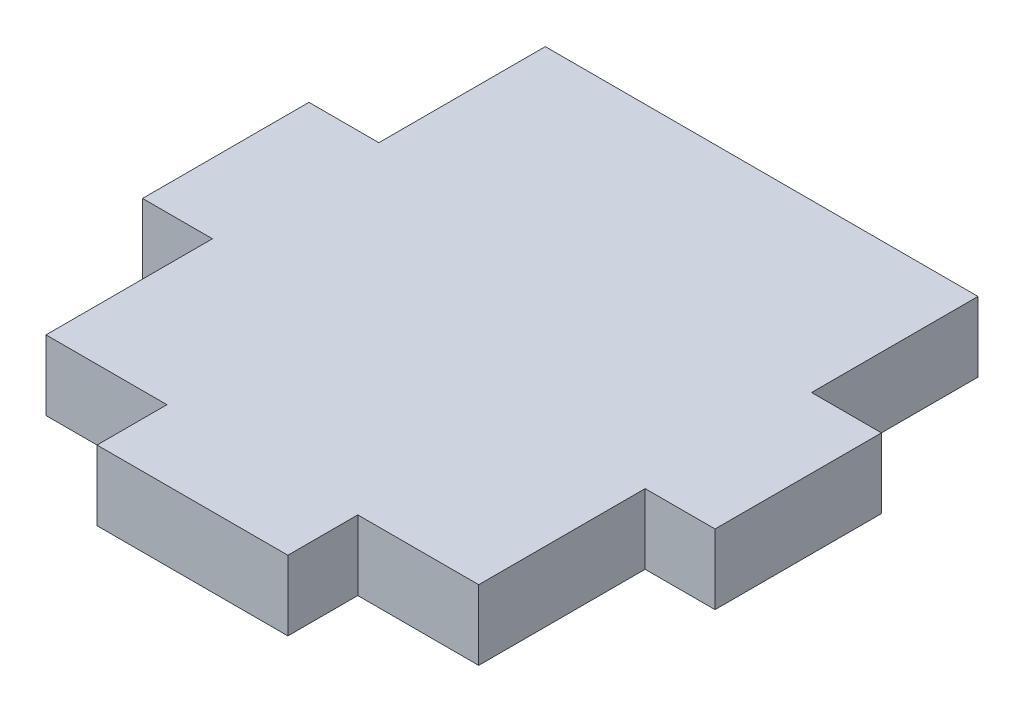
from build123d import *

# Parameters (mm, degrees)
SKETCH1_W           = 33.02
SKETCH1_H           = 38.1
BOSS_EXTRUDE1_DEPTH = 2.667
SKETCH2_W           = 14.562666666
SKETCH2_H           = 5.334
SKETCH2_W_2         = 5.334
SKETCH2_H_2         = 12.7
BOSS_EXTRUDE2_DEPTH = 5.334


with BuildPart() as part:
    # Sketch1 → Boss-Extrude1 (new body, symmetric)
    with BuildSketch(Plane(origin=(0, 0, 0), x_dir=(1, 0, 0), z_dir=(0, 1, 0))):
        Rectangle(SKETCH1_W, SKETCH1_H)
    extrude(amount=BOSS_EXTRUDE1_DEPTH, both=True)

    # Sketch2 → Boss-Extrude2 (add)
    with BuildSketch(Plane(origin=(0, 2.667, 0), x_dir=(1, 0, 0), z_dir=(0, 1, 0))):
        with Locations((0, -21.717)):
            Rectangle(SKETCH2_W, SKETCH2_H)
        with Locations((-19.177, 0)):
            Rectangle(SKETCH2_W_2, SKETCH2_H_2)
        with Locations((19.177, 0)):
            Rectangle(SKETCH2_W_2, SKETCH2_H_2)
    extrude(amount=-BOSS_EXTRUDE2_DEPTH)


solid = part.part
